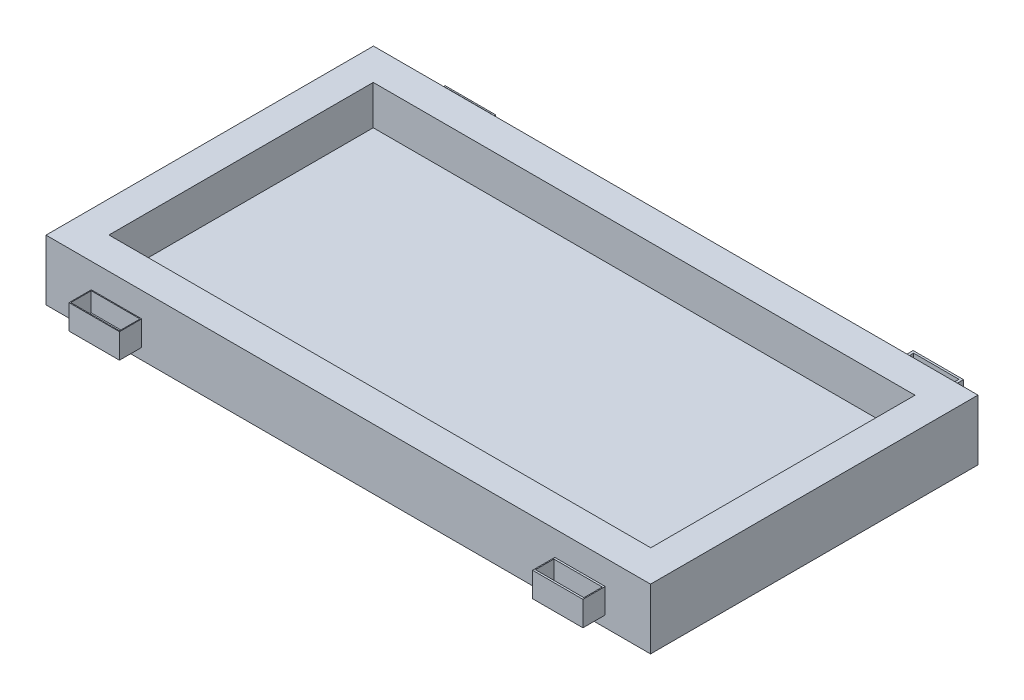
from build123d import *

# Parameters (mm, degrees)
SKETCH1_W                = 1200
SKETCH1_H                = 650
BOSS_EXTRUDE1_DEPTH      = 120
SKETCH6_W                = 1075.440948148
SKETCH6_H                = 524.60534056
CUT_EXTRUDE5_DEPTH       = 78
SKETCH2_W                = 100
SKETCH2_H                = 61.240681987
SKETCH2_H_2              = 52.060088527
SKETCH2_H_3              = 44.191008419
BOSS_EXTRUDE3_DEPTH      = 98
SKETCH7_W                = 44.191008419
SKETCH7_H                = 49
CUT_EXTRUDE6_DEPTH       = 91
CUT_EXTRUDE6_DEPTH_BACK  = 1111
SKETCH8_W                = 61.240681987
SKETCH8_H                = 49
CUT_EXTRUDE7_DEPTH       = 91
CUT_EXTRUDE7_DEPTH_BACK  = 1111
SKETCH10_W               = 96.846541068
SKETCH10_H               = 40.58098524
SKETCH10_W_2             = 96.178240502
SKETCH10_H_2             = 36.675881957
SKETCH10_W_3             = 89.939369206
SKETCH10_H_3             = 53.297884326
SKETCH10_W_4             = 93.422548206
SKETCH10_H_4             = 37.665233543
CUT_EXTRUDE9_DEPTH       = 38
SKETCH11_R               = 12.656806897
SKETCH11_R_2             = 13.624607795
SKETCH11_R_3             = 12.31829203
SKETCH11_R_4             = 17.162338859
CUT_EXTRUDE10_DEPTH      = 88
CUT_EXTRUDE10_DEPTH_BACK = 34


with BuildPart() as part:
    # Sketch1 → Boss-Extrude1 (new body)
    with BuildSketch(Plane(origin=(0, 0, 0), x_dir=(1, 0, 0), z_dir=(0, 1, 0))):
        Rectangle(SKETCH1_W, SKETCH1_H)
    extrude(amount=BOSS_EXTRUDE1_DEPTH)

    # Sketch6 → Cut-Extrude5 (cut)
    with BuildSketch(Plane(origin=(0, 120, 0), x_dir=(1, 0, 0), z_dir=(0, 1, 0))):
        Rectangle(SKETCH6_W, SKETCH6_H)
    extrude(amount=-CUT_EXTRUDE5_DEPTH, mode=Mode.SUBTRACT)

    # Sketch2 → Boss-Extrude3 (add)
    with BuildSketch(Plane(origin=(0, 120, 0), x_dir=(1, 0, 0), z_dir=(0, 1, 0))):
        with Locations((460, 355.620340994)):
            Rectangle(SKETCH2_W, SKETCH2_H)
        with Locations((-460, 351.030044264)):
            Rectangle(SKETCH2_W, SKETCH2_H_2)
        with Locations((-460, -347.09550421)):
            Rectangle(SKETCH2_W, SKETCH2_H_3)
        with Locations((460, -347.09550421)):
            Rectangle(SKETCH2_W, SKETCH2_H_3)
    extrude(amount=-BOSS_EXTRUDE3_DEPTH)

    # Sketch7 → Cut-Extrude6 (cut, two sides)
    with BuildSketch(Plane(origin=(510, 0, 0), x_dir=(0, 0, -1), z_dir=(1, 0, 0))) as cut_extrude6_sk:
        with Locations((-347.09550421, 95.5)):
            Rectangle(SKETCH7_W, SKETCH7_H)
    extrude(amount=CUT_EXTRUDE6_DEPTH, mode=Mode.SUBTRACT)
    extrude(cut_extrude6_sk.sketch, amount=-CUT_EXTRUDE6_DEPTH_BACK, mode=Mode.SUBTRACT)

    # Sketch8 → Cut-Extrude7 (cut, two sides)
    with BuildSketch(Plane(origin=(510, 0, 0), x_dir=(0, 0, -1), z_dir=(1, 0, 0))) as cut_extrude7_sk:
        with Locations((355.620340994, 95.5)):
            Rectangle(SKETCH8_W, SKETCH8_H)
    extrude(amount=CUT_EXTRUDE7_DEPTH, mode=Mode.SUBTRACT)
    extrude(cut_extrude7_sk.sketch, amount=-CUT_EXTRUDE7_DEPTH_BACK, mode=Mode.SUBTRACT)

    # Sketch10 → Cut-Extrude9 (cut)
    with BuildSketch(Plane(origin=(0, 71, 0), x_dir=(1, 0, 0), z_dir=(0, 1, 0))):
        with Locations((-460, -347.095504209)):
            Rectangle(SKETCH10_W, SKETCH10_H)
        with Locations((460, -347.09550421)):
            Rectangle(SKETCH10_W_2, SKETCH10_H_2)
        with Locations((460, 355.620340993)):
            Rectangle(SKETCH10_W_3, SKETCH10_H_3)
        with Locations((-460, 355.620340994)):
            Rectangle(SKETCH10_W_4, SKETCH10_H_4)
    extrude(amount=-CUT_EXTRUDE9_DEPTH, mode=Mode.SUBTRACT)

    # Sketch11 → Cut-Extrude10 (cut, two sides)
    with BuildSketch(Plane(origin=(0, 33, 0), x_dir=(1, 0, 0), z_dir=(0, 1, 0))) as cut_extrude10_sk:
        with Locations((-462.307183801, 358.120386365)):
            Circle(SKETCH11_R)
        with Locations((-462.307183801, -349.182945784)):
            Circle(SKETCH11_R_2)
        with Locations((463.409280552, -349.182945784)):
            Circle(SKETCH11_R_3)
        with Locations((467.367852557, 358.120386365)):
            Circle(SKETCH11_R_4)
    extrude(amount=CUT_EXTRUDE10_DEPTH, mode=Mode.SUBTRACT)
    extrude(cut_extrude10_sk.sketch, amount=-CUT_EXTRUDE10_DEPTH_BACK, mode=Mode.SUBTRACT)


solid = part.part
